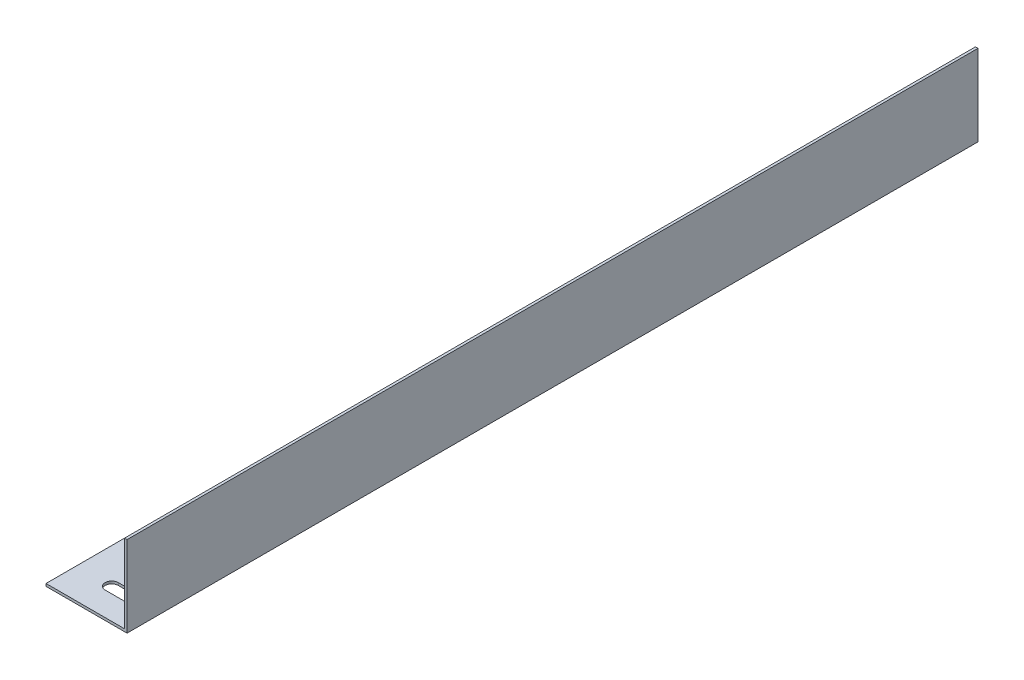
from build123d import *

# Parameters (mm, degrees)
EXTRUDE1_DEPTH     = 533.4
SKETCH2_R          = 4.1021
CUT_EXTRUDE1_DEPTH = 51.8


with BuildPart() as part:
    # Sketch1 → Extrude1 (new body)
    with BuildSketch(Plane.XY):
        Polygon((0, 0), (50.8, 0), (50.8, 50.8), (49.2125, 50.8), (49.2125, 1.5875), (0, 1.5875), align=None)
    extrude(amount=EXTRUDE1_DEPTH)

    # Sketch2 → Cut-Extrude1 (cut, through all)
    with BuildSketch(Plane.XZ):
        with Locations((22.1615, 57.15)):
            Circle(SKETCH2_R)
        with Locations((22.1615, 476.25)):
            Circle(SKETCH2_R)
        with Locations((22.1615, 19.05)):
            Circle(SKETCH2_R)
        with BuildLine():
            Line((22.1615, 518.4521), (34.8615, 518.4521))
            ThreePointArc((34.8615, 518.4521), (38.9636, 514.35), (34.8615, 510.2479))
            Line((34.8615, 510.2479), (22.1615, 510.2479))
            ThreePointArc((22.1615, 510.2479), (18.0594, 514.35), (22.1615, 518.4521))
        make_face()
    extrude(amount=-CUT_EXTRUDE1_DEPTH, mode=Mode.SUBTRACT)


solid = part.part
